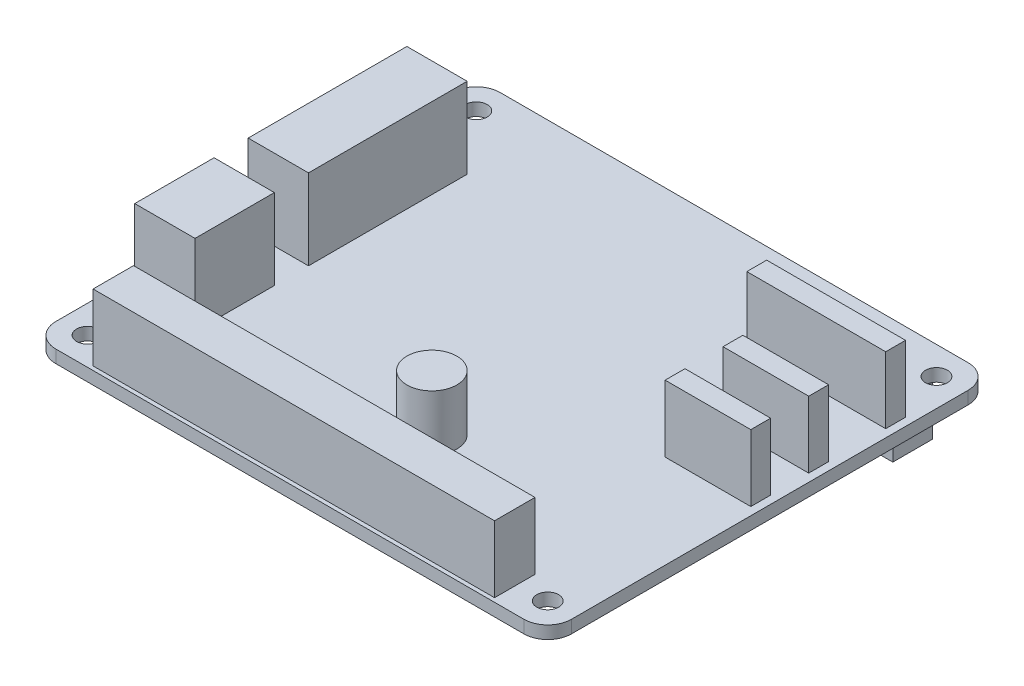
from build123d import *

# Parameters (mm, degrees)
SKETCH1_R           = 1.375
BOSS_EXTRUDE1_DEPTH = 1.6
SKETCH2_W           = 7.6
SKETCH2_H           = 20
SKETCH2_H_2         = 10
BOSS_EXTRUDE2_DEPTH = 10.15
SKETCH3_W           = 50.6
SKETCH3_H           = 5.1
BOSS_EXTRUDE3_DEPTH = 8.4
SKETCH4_R           = 3.15
BOSS_EXTRUDE4_DEPTH = 7
SKETCH5_W           = 17.5
SKETCH5_H           = 2.5
SKETCH5_W_2         = 10.8
BOSS_EXTRUDE5_DEPTH = 8.4
SKETCH6_W           = 52
SKETCH6_H           = 5
BOSS_EXTRUDE6_DEPTH = 8


with BuildPart() as part:
    # Sketch1 → Boss-Extrude1 (new body)
    with BuildSketch(Plane(origin=(0, 0, 0), x_dir=(1, 0, 0), z_dir=(0, 1, 0))):
        with BuildLine():
            Line((3, 0), (62, 0))
            ThreePointArc((62, 0), (64.121320344, 0.878679656), (65, 3))
            Line((65, 3), (65, 53))
            ThreePointArc((65, 53), (64.121320344, 55.121320344), (62, 56))
            Line((62, 56), (3, 56))
            ThreePointArc((3, 56), (0.878679656, 55.121320344), (0, 53))
            Line((0, 53), (0, 3))
            ThreePointArc((0, 3), (0.878679656, 0.878679656), (3, 0))
        make_face()
        with Locations((3.5, 52.5)):
            Circle(SKETCH1_R, mode=Mode.SUBTRACT)
        with Locations((61.5, 52.5)):
            Circle(SKETCH1_R, mode=Mode.SUBTRACT)
        with Locations((3.5, 3.5)):
            Circle(SKETCH1_R, mode=Mode.SUBTRACT)
        with Locations((61.5, 3.5)):
            Circle(SKETCH1_R, mode=Mode.SUBTRACT)
    extrude(amount=BOSS_EXTRUDE1_DEPTH)

    # Sketch2 → Boss-Extrude2 (add)
    with BuildSketch(Plane(origin=(0, 1.6, 0), x_dir=(1, 0, 0), z_dir=(0, 1, 0))):
        with Locations((6.05, 35)):
            Rectangle(SKETCH2_W, SKETCH2_H)
        with Locations((6.05, 15.7)):
            Rectangle(SKETCH2_W, SKETCH2_H_2)
    extrude(amount=BOSS_EXTRUDE2_DEPTH)

    # Sketch3 → Boss-Extrude3 (add)
    with BuildSketch(Plane(origin=(0, 1.6, 0), x_dir=(1, 0, 0), z_dir=(0, 1, 0))):
        with Locations((32.5, 3.05)):
            Rectangle(SKETCH3_W, SKETCH3_H)
    extrude(amount=BOSS_EXTRUDE3_DEPTH)

    # Sketch4 → Boss-Extrude4 (add)
    with BuildSketch(Plane(origin=(0, 1.6, 0), x_dir=(1, 0, 0), z_dir=(0, 1, 0))):
        with Locations((36.05, 14.35)):
            Circle(SKETCH4_R)
    extrude(amount=BOSS_EXTRUDE4_DEPTH)

    # Sketch5 → Boss-Extrude5 (add)
    with BuildSketch(Plane(origin=(0, 1.6, 0), x_dir=(1, 0, 0), z_dir=(0, 1, 0))):
        with Locations((55.25, 44.85)):
            Rectangle(SKETCH5_W, SKETCH5_H)
        with Locations((58.6, 35.15)):
            Rectangle(SKETCH5_W_2, SKETCH5_H)
        with Locations((58.6, 27.85)):
            Rectangle(SKETCH5_W_2, SKETCH5_H)
    extrude(amount=BOSS_EXTRUDE5_DEPTH)

    # Sketch6 → Boss-Extrude6 (add)
    with BuildSketch(Plane.XZ):
        with Locations((32.5, -52.5)):
            Rectangle(SKETCH6_W, SKETCH6_H)
    extrude(amount=BOSS_EXTRUDE6_DEPTH)


solid = part.part
